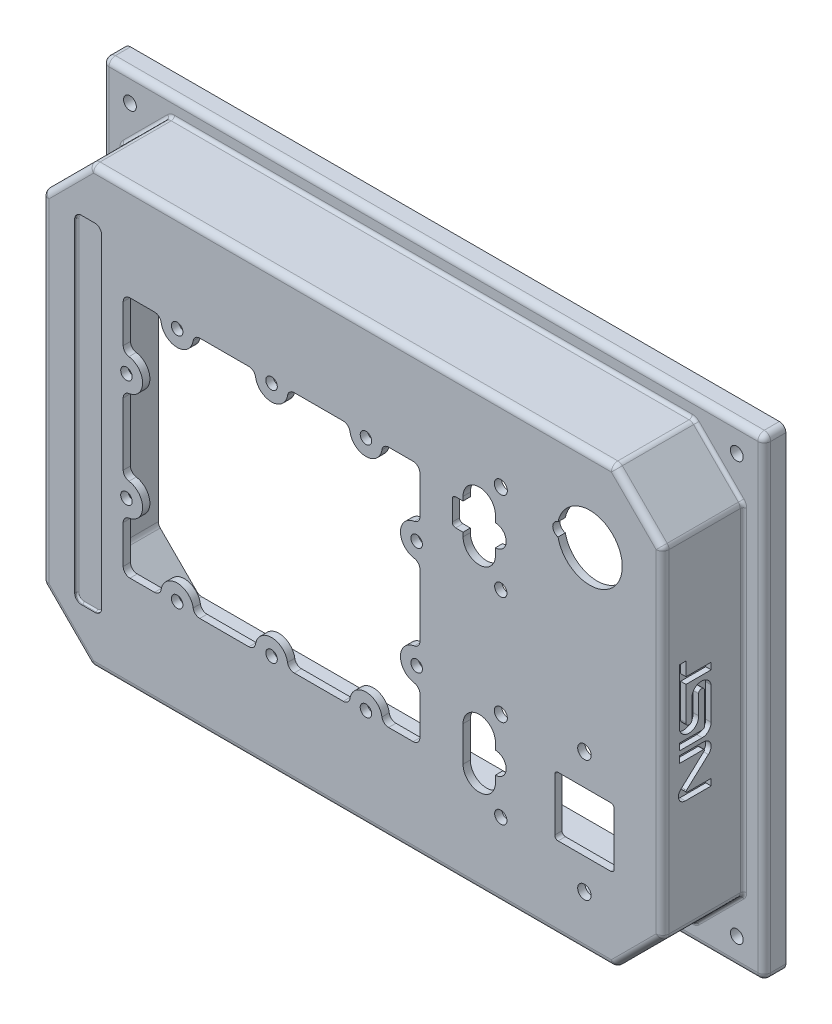
from build123d import *

# Parameters (mm, degrees)
SKETCH1_W                        = 311.6072
SKETCH1_H                        = 222.7072
BOSS_EXTRUDE1_DEPTH              = 10.16
BOSS_EXTRUDE2_DEPTH              = 38.1
F_15_64_0_23438_DIAMETER_HOLE1_D = 6.0325
LPATTERN1_COUNT                  = 2
LPATTERN1_PITCH                  = 285.75
LPATTERN1_COUNT_DIR2             = 2
LPATTERN1_PITCH_DIR2             = 196.85
CUT_EXTRUDE1_DEPTH               = 44.831
CUT_EXTRUDE2_DEPTH               = 49.26
F_1_4_0_25_DIAMETER_HOLE1_D      = 5.4102
F_1_4_0_25_DIAMETER_HOLE1_DEPTH  = 3.43
LPATTERN2_COUNT                  = 3
LPATTERN2_PITCH                  = 44.45
LPATTERN2_COUNT_DIR2             = 2
LPATTERN2_PITCH_DIR2             = 111.252
F_1_4_0_25_DIAMETER_HOLE2_D      = 5.4102
F_1_4_0_25_DIAMETER_HOLE2_DEPTH  = 3.43
LPATTERN3_COUNT                  = 2
LPATTERN3_PITCH                  = 136.652
LPATTERN3_COUNT_DIR2             = 2
LPATTERN3_PITCH_DIR2             = 50.8
SKETCH15_W                       = 27.94
SKETCH15_H                       = 27.94
CUT_EXTRUDE3_DEPTH               = 44.831
F_1_4_0_25_DIAMETER_HOLE3_D      = 6.35
F_1_4_0_25_DIAMETER_HOLE3_DEPTH  = 3.429
LPATTERN4_COUNT                  = 2
LPATTERN4_PITCH                  = 57.15
F_1_4_0_25_DIAMETER_HOLE4_D      = 5.7912
F_1_4_0_25_DIAMETER_HOLE4_DEPTH  = 3.429
LPATTERN5_COUNT                  = 2
LPATTERN5_PITCH                  = 92.71
F_1_4_0_25_DIAMETER_HOLE5_D      = 6.1468
LPATTERN6_COUNT                  = 2
LPATTERN6_PITCH                  = 92.71
CUT_EXTRUDE4_DEPTH               = 44.831
SKETCH23_W                       = 12.7
SKETCH23_H                       = 158.75
CUT_EXTRUDE5_DEPTH               = 1.27
CUT_EXTRUDE6_REACH               = 50.26
FILLET1_R                        = 3.175
FILLET2_R                        = 3.175
FILLET3_R                        = 0.762
FILLET4_R                        = 1.5875
FILLET5_R                        = 1.5875
FILLET7_R                        = 3.048
FILLET6_R                        = 1.524
FILLET8_R                        = 3.048
FILLET9_R                        = 3.048
CUT_EXTRUDE7_DEPTH               = 2.54


with BuildPart() as part:
    # Sketch1 → Boss-Extrude1 (new body)
    with BuildSketch(Plane.XY):
        Rectangle(SKETCH1_W, SKETCH1_H)
    extrude(amount=BOSS_EXTRUDE1_DEPTH)

    # Sketch2 → Boss-Extrude2 (add)
    with BuildSketch(Plane.XY.offset(10.16)):
        Polygon((-123.1646, 102.4636), (123.1646, 102.4636), (146.0246, 79.6036), (146.0246, -79.6036), (123.1646, -102.4636), (-123.1646, -102.4636), (-146.0246, -79.6036), (-146.0246, 79.6036), align=None)
    extrude(amount=BOSS_EXTRUDE2_DEPTH)

    # 15_64 _0.23438_ Diameter Hole1 (through all)
    with Locations(Plane.XY.offset(10.16)):
        with Locations((-142.875, 98.425)):
            f_15_64_0_23438_diameter_hole1 = Hole(F_15_64_0_23438_DIAMETER_HOLE1_D / 2)

    # LPattern1: 15_64 _0.23438_ Diameter Hole1 2 × 2
    with Locations(*[(i * LPATTERN1_PITCH, -j * LPATTERN1_PITCH_DIR2, 0) for i in range(LPATTERN1_COUNT) for j in range(LPATTERN1_COUNT_DIR2) if (i, j) != (0, 0)]):
        add(f_15_64_0_23438_diameter_hole1, mode=Mode.SUBTRACT)

    # Sketch9 → Cut-Extrude1 (cut)
    with BuildSketch(Plane.XY):
        Polygon((-120.534343879, 96.1136), (-139.6746, 76.973343879), (-139.6746, -76.973343879), (-120.534343879, -96.1136), (120.534343879, -96.1136), (139.6746, -76.973343879), (139.6746, 76.973343879), (120.534343879, 96.1136), align=None)
    extrude(amount=CUT_EXTRUDE1_DEPTH, mode=Mode.SUBTRACT)

    # Sketch10 → Cut-Extrude2 (cut, through all)
    with BuildSketch(Plane.XY.offset(48.26)):
        with BuildLine():
            Line((-45.72, -55.626), (-45.72, -57.15))
            Line((-45.72, -57.15), (-74.93, -57.15))
            Line((-74.93, -57.15), (-74.93, -55.626))
            ThreePointArc((-74.93, -55.626), (-82.55, -48.006), (-90.17, -55.626))
            Line((-90.17, -55.626), (-90.17, -57.15))
            Line((-90.17, -57.15), (-107.95, -57.15))
            Line((-107.95, -57.15), (-107.95, -33.02))
            Line((-107.95, -33.02), (-106.426, -33.02))
            ThreePointArc((-106.426, -33.02), (-98.806, -25.4), (-106.426, -17.78))
            Line((-106.426, -17.78), (-107.95, -17.78))
            Line((-107.95, -17.78), (-107.95, 17.78))
            Line((-107.95, 17.78), (-106.426, 17.78))
            ThreePointArc((-106.426, 17.78), (-98.806, 25.4), (-106.426, 33.02))
            Line((-106.426, 33.02), (-107.95, 33.02))
            Line((-107.95, 33.02), (-107.95, 57.15))
            Line((-107.95, 57.15), (-90.17, 57.15))
            Line((-90.17, 57.15), (-90.17, 55.626))
            ThreePointArc((-90.17, 55.626), (-82.55, 48.006), (-74.93, 55.626))
            Line((-74.93, 55.626), (-74.93, 57.15))
            Line((-74.93, 57.15), (-45.72, 57.15))
            Line((-45.72, 57.15), (-45.72, 55.626))
            ThreePointArc((-45.72, 55.626), (-38.1, 48.006), (-30.48, 55.626))
            Line((-30.48, 55.626), (-30.48, 57.15))
            Line((-30.48, 57.15), (-1.27, 57.15))
            Line((-1.27, 57.15), (-1.27, 55.626))
            ThreePointArc((-1.27, 55.626), (6.35, 48.006), (13.97, 55.626))
            Line((13.97, 55.626), (13.97, 57.15))
            Line((13.97, 57.15), (31.75, 57.15))
            Line((31.75, 57.15), (31.75, 33.02))
            Line((31.75, 33.02), (30.226, 33.02))
            ThreePointArc((30.226, 33.02), (22.606, 25.4), (30.226, 17.78))
            Line((30.226, 17.78), (31.75, 17.78))
            Line((31.75, 17.78), (31.75, -17.78))
            Line((31.75, -17.78), (30.226, -17.78))
            ThreePointArc((30.226, -17.78), (22.606, -25.4), (30.226, -33.02))
            Line((30.226, -33.02), (31.75, -33.02))
            Line((31.75, -33.02), (31.75, -57.15))
            Line((31.75, -57.15), (13.97, -57.15))
            Line((13.97, -57.15), (13.97, -55.626))
            ThreePointArc((13.97, -55.626), (6.35, -48.006), (-1.27, -55.626))
            Line((-1.27, -55.626), (-1.27, -57.15))
            Line((-1.27, -57.15), (-30.48, -57.15))
            Line((-30.48, -57.15), (-30.48, -55.626))
            ThreePointArc((-30.48, -55.626), (-38.1, -48.006), (-45.72, -55.626))
        make_face()
    extrude(amount=-CUT_EXTRUDE2_DEPTH, mode=Mode.SUBTRACT)

    # 1_4 _0.25_ Diameter Hole1
    with Locations(Plane.XY.offset(48.26)):
        with Locations((-82.55, 55.626)):
            f_1_4_0_25_diameter_hole1 = Hole(F_1_4_0_25_DIAMETER_HOLE1_D / 2, depth=F_1_4_0_25_DIAMETER_HOLE1_DEPTH)

    # LPattern2: 1_4 _0.25_ Diameter Hole1 3 × 2
    with Locations(*[(i * LPATTERN2_PITCH, -j * LPATTERN2_PITCH_DIR2, 0) for i in range(LPATTERN2_COUNT) for j in range(LPATTERN2_COUNT_DIR2) if (i, j) != (0, 0)]):
        add(f_1_4_0_25_diameter_hole1, mode=Mode.SUBTRACT)

    # 1_4 _0.25_ Diameter Hole2
    with Locations(Plane.XY.offset(48.26)):
        with Locations((-106.426, 25.4)):
            f_1_4_0_25_diameter_hole2 = Hole(F_1_4_0_25_DIAMETER_HOLE2_D / 2, depth=F_1_4_0_25_DIAMETER_HOLE2_DEPTH)

    # LPattern3: 1_4 _0.25_ Diameter Hole2 2 × 2
    with Locations(*[(i * LPATTERN3_PITCH, -j * LPATTERN3_PITCH_DIR2, 0) for i in range(LPATTERN3_COUNT) for j in range(LPATTERN3_COUNT_DIR2) if (i, j) != (0, 0)]):
        add(f_1_4_0_25_diameter_hole2, mode=Mode.SUBTRACT)

    # Sketch15 → Cut-Extrude3 (cut)
    with BuildSketch(Plane.XY.offset(48.26)):
        with Locations((109.22, -49.53)):
            Rectangle(SKETCH15_W, SKETCH15_H)
    extrude(amount=-CUT_EXTRUDE3_DEPTH, mode=Mode.SUBTRACT)

    # 1_4 _0.25_ Diameter Hole3
    with Locations(Plane.XY.offset(48.26)):
        with Locations((109.22, -20.955)):
            f_1_4_0_25_diameter_hole3 = Hole(F_1_4_0_25_DIAMETER_HOLE3_D / 2, depth=F_1_4_0_25_DIAMETER_HOLE3_DEPTH)

    # LPattern4: 1_4 _0.25_ Diameter Hole3 ×2
    with Locations(*[(0, -i * LPATTERN4_PITCH, 0) for i in range(1, LPATTERN4_COUNT)]):
        add(f_1_4_0_25_diameter_hole3, mode=Mode.SUBTRACT)

    # 1_4 _0.25_ Diameter Hole4
    with Locations(Plane.XY.offset(48.26)):
        with Locations((69.85, 25.4)):
            f_1_4_0_25_diameter_hole4 = Hole(F_1_4_0_25_DIAMETER_HOLE4_D / 2, depth=F_1_4_0_25_DIAMETER_HOLE4_DEPTH)

    # LPattern5: 1_4 _0.25_ Diameter Hole4 ×2
    with Locations(*[(0, -i * LPATTERN5_PITCH, 0) for i in range(1, LPATTERN5_COUNT)]):
        add(f_1_4_0_25_diameter_hole4, mode=Mode.SUBTRACT)

    # 1_4 _0.25_ Diameter Hole5 (through all)
    with Locations(Plane.XY.offset(48.26)):
        with Locations((69.85, 67.31)):
            f_1_4_0_25_diameter_hole5 = Hole(F_1_4_0_25_DIAMETER_HOLE5_D / 2)

    # LPattern6: 1_4 _0.25_ Diameter Hole5 ×2
    with Locations(*[(0, -i * LPATTERN6_PITCH, 0) for i in range(1, LPATTERN6_COUNT)]):
        add(f_1_4_0_25_diameter_hole5, mode=Mode.SUBTRACT)

    # Sketch22 → Cut-Extrude4 (cut)
    with BuildSketch(Plane.XY.offset(48.26)):
        with BuildLine():
            Line((67.31, 54.61), (67.31, 51.435))
            ThreePointArc((67.31, 51.435), (72.39, 46.355), (67.31, 41.275))
            Line((67.31, 41.275), (67.31, 38.1))
            ThreePointArc((67.31, 38.1), (59.69, 30.48), (52.07, 38.1))
            Line((52.07, 38.1), (52.07, 40.005))
            Line((52.07, 40.005), (46.99, 40.005))
            Line((46.99, 40.005), (46.99, 52.705))
            Line((46.99, 52.705), (52.07, 52.705))
            Line((52.07, 52.705), (52.07, 54.61))
            ThreePointArc((52.07, 54.61), (59.69, 62.23), (67.31, 54.61))
        make_face()
        with BuildLine():
            Line((67.31, -41.275), (67.31, -38.1))
            ThreePointArc((67.31, -38.1), (59.69, -30.48), (52.07, -38.1))
            Line((52.07, -38.1), (52.07, -54.61))
            ThreePointArc((52.07, -54.61), (59.69, -62.23), (67.31, -54.61))
            Line((67.31, -54.61), (67.31, -51.435))
            ThreePointArc((67.31, -51.435), (72.39, -46.355), (67.31, -41.275))
        make_face()
    extrude(amount=-CUT_EXTRUDE4_DEPTH, mode=Mode.SUBTRACT)

    # Sketch23 → Cut-Extrude5 (cut)
    with BuildSketch(Plane.XY.offset(48.26)):
        with Locations((-124.46, 0)):
            Rectangle(SKETCH23_W, SKETCH23_H)
    extrude(amount=-CUT_EXTRUDE5_DEPTH, mode=Mode.SUBTRACT)

    # Sketch24 → Cut-Extrude6 (cut, up to next)
    with BuildSketch(Plane.XY.offset(48.26), mode=Mode.PRIVATE) as cut_extrude6_sk1:
        with BuildLine():
            ThreePointArc((96.798978868, 60.397260197), (127.03937, 63.5), (96.798978868, 66.602739803))
            ThreePointArc((96.798978868, 66.602739803), (94.2975, 63.5), (96.798978868, 60.397260197))
        make_face()
    cut_extrude6_tool1 = extrude(cut_extrude6_sk1.sketch, amount=-CUT_EXTRUDE6_REACH, mode=Mode.PRIVATE) & part.part
    add(cut_extrude6_tool1.solids().sort_by_distance((111.53734, 63.5, 48.26))[0], mode=Mode.SUBTRACT)

    # Fillet1
    fillet1_edges = [part.edges().sort_by_distance(p)[0] for p in [
        (-107.95, -57.15, 46.5455),
        (-74.93, -57.15, 46.5455),
        (-90.17, -57.15, 46.5455),
        (-45.72, -57.15, 46.5455),
        (-1.27, -57.15, 46.5455),
        (-30.48, -57.15, 46.5455),
        (13.97, -57.15, 46.5455),
        (31.75, -57.15, 46.5455),
        (31.75, 33.02, 46.5455),
        (31.75, -17.78, 46.5455),
        (31.75, -33.02, 46.5455),
        (31.75, 17.78, 46.5455),
        (-90.17, 57.15, 46.5455),
        (-45.72, 57.15, 46.5455),
        (-1.27, 57.15, 46.5455),
        (31.75, 57.15, 46.5455),
        (-107.95, 33.02, 46.5455),
        (-107.95, -17.78, 46.5455),
        (-107.95, -33.02, 46.5455),
        (-107.95, 17.78, 46.5455),
        (13.97, 57.15, 46.5455),
        (-30.48, 57.15, 46.5455),
        (-74.93, 57.15, 46.5455),
        (-107.95, 57.15, 46.5455),
    ]]
    fillet(fillet1_edges, radius=FILLET1_R)

    # Fillet2
    fillet2_edges = [part.edges().sort_by_distance(p)[0] for p in [
        (-130.81, -79.375, 47.625),
        (-130.81, 79.375, 47.625),
        (-118.11, 79.375, 47.625),
        (-118.11, -79.375, 47.625),
    ]]
    fillet(fillet2_edges, radius=FILLET2_R)

    # Fillet3
    fillet3_edges = [part.edges().sort_by_distance(p)[0] for p in [
        (-124.46, -79.375, 46.99),
        (-130.81, 0, 46.99),
        (-118.11, 0, 46.99),
        (-124.46, 79.375, 46.99),
        (-129.88006403, 78.44506403, 46.99),
        (-119.03993597, 78.44506403, 46.99),
        (-119.03993597, -78.44506403, 46.99),
        (-129.88006403, -78.44506403, 46.99),
    ]]
    fillet(fillet3_edges, radius=FILLET3_R)

    # Fillet4
    fillet4_edges = [part.edges().sort_by_distance(p)[0] for p in [
        (46.99, 40.005, 46.5455),
        (46.99, 52.705, 46.5455),
    ]]
    fillet(fillet4_edges, radius=FILLET4_R)

    # Fillet5
    fillet5_edges = [part.edges().sort_by_distance(p)[0] for p in [
        (95.25, -63.5, 46.5455),
        (95.25, -35.56, 46.5455),
        (123.19, -35.56, 46.5455),
        (123.19, -63.5, 46.5455),
    ]]
    fillet(fillet5_edges, radius=FILLET5_R)

    # Fillet7
    fillet7_edges = [part.edges().sort_by_distance(p)[0] for p in [
        (-123.1646, 102.4636, 29.21),
        (-146.0246, 79.6036, 29.21),
        (-146.0246, -79.6036, 29.21),
        (-123.1646, -102.4636, 29.21),
        (123.1646, -102.4636, 29.21),
        (146.0246, -79.6036, 29.21),
        (146.0246, 79.6036, 29.21),
        (123.1646, 102.4636, 29.21),
        (-134.5946, 91.0336, 48.26),
        (-146.0246, 0, 48.26),
        (-134.5946, -91.0336, 48.26),
        (0, -102.4636, 48.26),
        (134.5946, -91.0336, 48.26),
        (146.0246, 0, 48.26),
        (134.5946, 91.0336, 48.26),
        (0, 102.4636, 48.26),
    ]]
    fillet(fillet7_edges, radius=FILLET7_R)

    # Fillet6
    fillet6_edges = [part.edges().sort_by_distance(p)[0] for p in [
        (134.5946, 91.0336, 10.16),
        (-134.5946, -91.0336, 10.16),
        (-146.0246, 0, 10.16),
        (0, -102.4636, 10.16),
        (134.5946, -91.0336, 10.16),
        (146.0246, 0, 10.16),
        (0, 102.4636, 10.16),
        (-134.5946, 91.0336, 10.16),
        (-145.792584815, -79.507496164, 10.16),
        (-123.068496164, -102.231584815, 10.16),
        (123.068496164, -102.231584815, 10.16),
        (145.792584815, -79.507496164, 10.16),
        (145.792584815, 79.507496164, 10.16),
        (123.068496164, 102.231584815, 10.16),
        (-123.068496164, 102.231584815, 10.16),
        (-145.792584815, 79.507496164, 10.16),
    ]]
    fillet(fillet6_edges, radius=FILLET6_R)

    # Fillet8
    fillet8_edges = [part.edges().sort_by_distance(p)[0] for p in [
        (155.8036, 0, 10.16),
        (0, 111.3536, 10.16),
        (-155.8036, 0, 10.16),
        (0, -111.3536, 10.16),
        (-155.8036, 111.3536, 5.08),
        (155.8036, 111.3536, 5.08),
        (155.8036, -111.3536, 5.08),
        (-155.8036, -111.3536, 5.08),
    ]]
    fillet(fillet8_edges, radius=FILLET8_R)

    # Fillet9
    fillet9_edges = [part.edges().sort_by_distance(p)[0] for p in [
        (120.534343879, 96.1136, 22.4155),
        (-120.534343879, 96.1136, 22.4155),
        (-139.6746, 76.973343879, 22.4155),
        (-139.6746, -76.973343879, 22.4155),
        (-120.534343879, -96.1136, 22.4155),
        (120.534343879, -96.1136, 22.4155),
        (139.6746, -76.973343879, 22.4155),
        (139.6746, 76.973343879, 22.4155),
        (0, 96.1136, 44.831),
        (-130.104471939, 86.543471939, 44.831),
        (-139.6746, 0, 44.831),
        (-130.104471939, -86.543471939, 44.831),
        (0, -96.1136, 44.831),
        (130.104471939, -86.543471939, 44.831),
        (139.6746, 0, 44.831),
        (130.104471939, 86.543471939, 44.831),
    ]]
    fillet(fillet9_edges, radius=FILLET9_R)

    # Sketch29 → Cut-Extrude7 (cut)
    with BuildSketch(Plane(origin=(146.0246, 0, 0), x_dir=(0, 0, -1), z_dir=(1, 0, 0))):
        with BuildLine():
            Line((-40.4, -6.1589015), (-29.595737694, -6.1589015))
            ThreePointArc((-29.595737694, -6.1589015), (-26.628903119, -4.929998381), (-25.4, -1.963163806))
            Line((-25.4, -1.963163806), (-25.4, 13.237322763))
            ThreePointArc((-25.4, 13.237322763), (-29.911464096, 17.08720584), (-34.422928193, 13.237322763))
            Line((-34.422928193, 13.237322763), (-34.422928193, 3.610561798))
            ThreePointArc((-34.422928193, 3.610561798), (-35.890845706, 2.20135799), (-37.238989334, 3.725544972))
            Line((-37.238989334, 3.725544972), (-37.238989334, 19.415615126))
            Line((-37.238989334, 19.415615126), (-25.4, 19.415615126))
            Line((-25.4, 19.415615126), (-25.4, 22.518107569))
            Line((-25.4, 22.518107569), (-37.238989334, 22.518107569))
            Line((-37.238989334, 22.518107569), (-37.238989334, 28.927392916))
            Line((-37.238989334, 28.927392916), (-40.4, 28.927392916))
            Line((-40.4, 28.927392916), (-40.4, 3.324130497))
            ThreePointArc((-40.4, 3.324130497), (-35.681192291, -1.219334765), (-31.31958022, 3.668053385))
            Line((-31.31958022, 3.668053385), (-31.31958022, 12.719898477))
            ThreePointArc((-31.31958022, 12.719898477), (-29.937198382, 14.013509006), (-28.503176866, 12.777390064))
            Line((-28.503176866, 12.777390064), (-28.503176866, -1.9340758))
            ThreePointArc((-28.503176866, -1.9340758), (-28.823180524, -2.70663297), (-29.595737694, -3.026636628))
            Line((-29.595737694, -3.026636628), (-40.4, -3.026636628))
            Line((-40.4, -3.026636628), (-40.4, -6.1589015))
        make_face()
        with BuildLine():
            Line((-25.4, -27.94), (-37.562091654, -27.94))
            ThreePointArc((-37.562091654, -27.94), (-40.598654454, -25.867827596), (-39.776078046, -22.284814875))
            Line((-39.776078046, -22.284814875), (-28.675651628, -12.019963497))
            ThreePointArc((-28.675651628, -12.019963497), (-28.57772605, -11.548341158), (-28.991855358, -11.302345292))
            Line((-28.991855358, -11.302345292), (-40.4, -11.302345292))
            Line((-40.4, -11.302345292), (-40.4, -8.17008042))
            Line((-40.4, -8.17008042), (-28.917141872, -8.17008042))
            ThreePointArc((-28.917141872, -8.17008042), (-25.598389368, -10.5226757), (-26.719424488, -14.433187559))
            Line((-26.719424488, -14.433187559), (-37.009022985, -23.900342617))
            ThreePointArc((-37.009022985, -23.900342617), (-37.146449936, -24.493816623), (-36.643484624, -24.837507557))
            Line((-36.643484624, -24.837507557), (-25.4, -24.837507557))
            Line((-25.4, -24.837507557), (-25.4, -27.94))
        make_face()
    extrude(amount=-CUT_EXTRUDE7_DEPTH, mode=Mode.SUBTRACT)


solid = part.part
